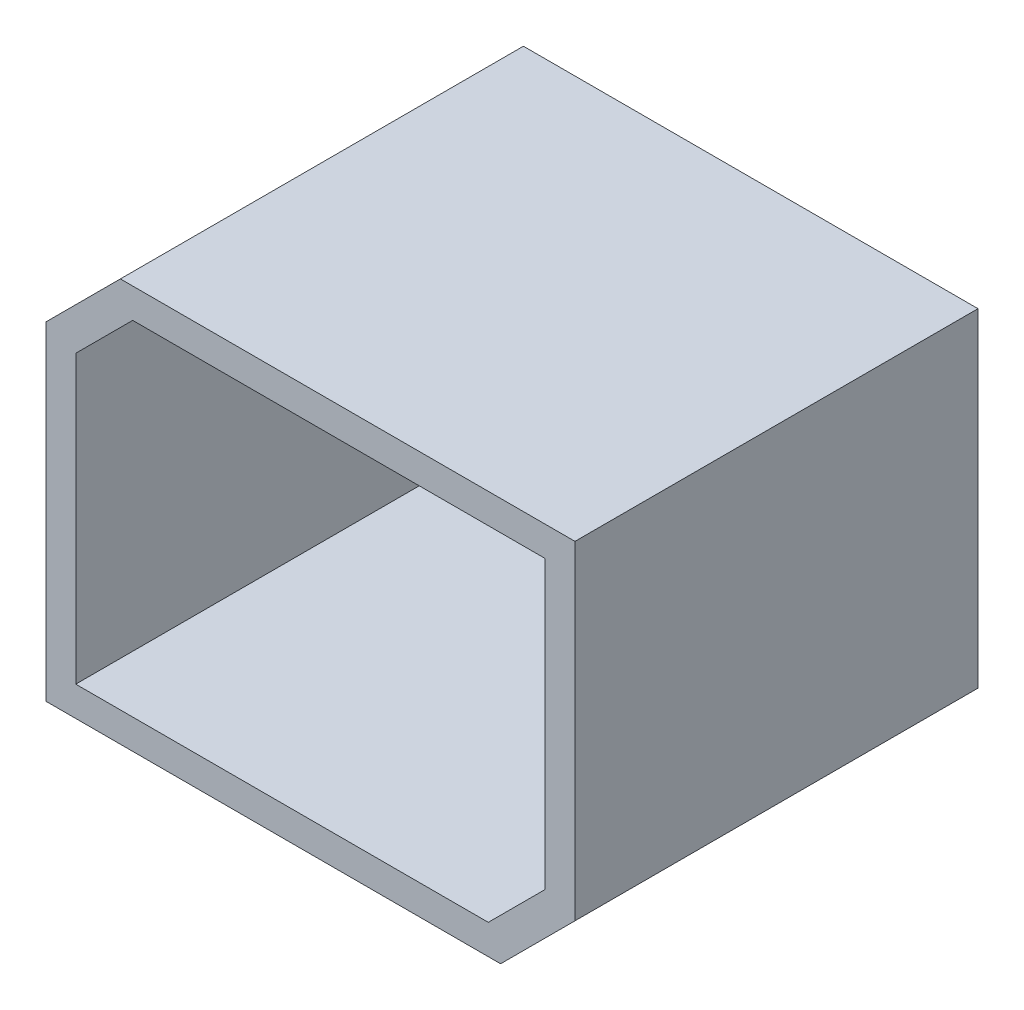
from build123d import *

# Parameters (mm, degrees)
SKETCH1_W           = 106.68
SKETCH1_H           = 81.28
BOSS_EXTRUDE1_DEPTH = 81.28
CHAMFER1_SIZE       = 15
SHELL2_T            = -6


with BuildPart() as part:
    # Sketch1 → Boss-Extrude1 (new body)
    with BuildSketch(Plane.XY):
        with Locations((53.34, 40.64)):
            Rectangle(SKETCH1_W, SKETCH1_H)
    extrude(amount=BOSS_EXTRUDE1_DEPTH)

    # Chamfer1
    chamfer1_edges = [part.edges().sort_by_distance(p)[0] for p in [
        (0, 81.28, 40.64),
        (106.68, 0, 40.64),
    ]]
    chamfer(chamfer1_edges, length=CHAMFER1_SIZE)

    # Shell2
    shell2_openings = [part.faces().sort_by_distance(p)[0] for p in [
        (53.34, 40.64, 81.28),
    ]]
    offset(amount=SHELL2_T, openings=shell2_openings, kind=Kind.INTERSECTION)


solid = part.part
